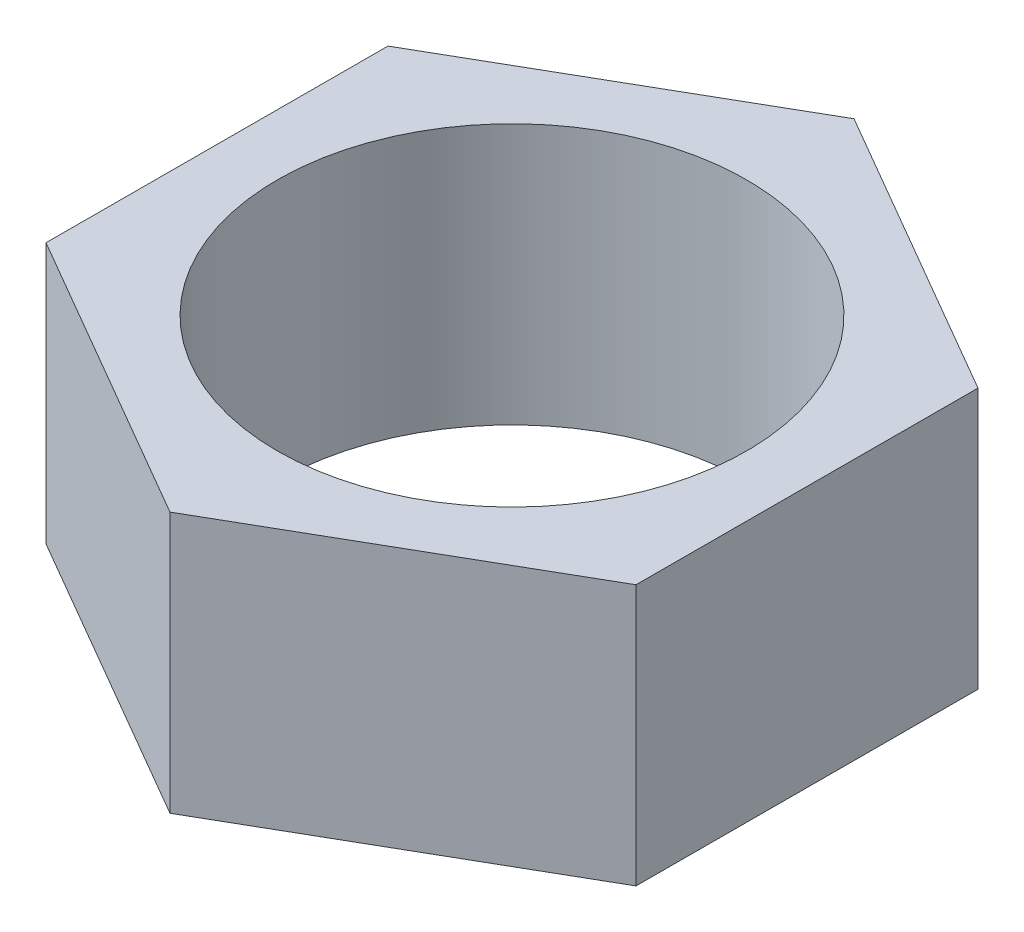
from build123d import *

# Parameters (mm, degrees)
SKETCH3_R           = 12.6
BOSS_EXTRUDE1_DEPTH = 7


with BuildPart() as part:
    # Sketch3 → Boss-Extrude1 (new body, symmetric)
    with BuildSketch(Plane(origin=(0, 0, 0), x_dir=(1, 0, 0), z_dir=(0, 1, 0))):
        Polygon((15.846834051, -9.192401784), (15.884270492, 9.127559966), (0.037436441, 18.31996175), (-15.846834051, 9.192401784), (-15.884270492, -9.127559966), (-0.037436441, -18.31996175), align=None)
        Circle(SKETCH3_R, mode=Mode.SUBTRACT)
    extrude(amount=BOSS_EXTRUDE1_DEPTH, both=True)


solid = part.part
